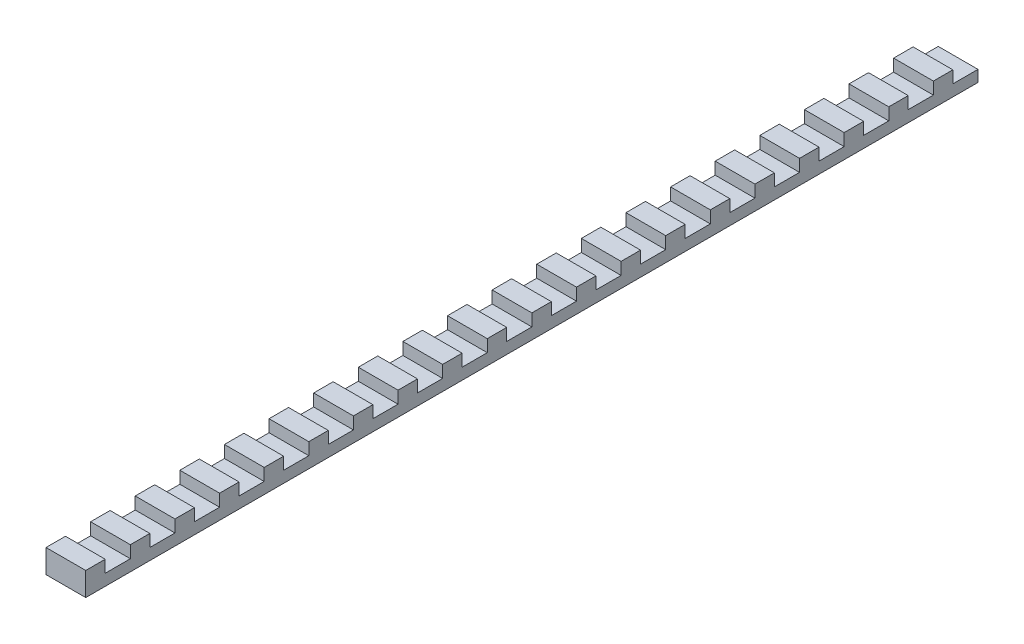
from build123d import *

# Parameters (mm, degrees)
BOSS_EXTRUDE1_DEPTH = 9.8
LPATTERN1_COUNT     = 20
LPATTERN1_PITCH     = 11


with BuildPart() as part:
    # Sketch1 → Boss-Extrude1 (new body)
    with BuildSketch(Plane(origin=(0, 0, 0), x_dir=(0, 0, -1), z_dir=(1, 0, 0))):
        Polygon((0, 0), (4.8, 0), (11, 0), (11, 2.8), (4.8, 2.8), (4.8, 5.8), (0, 5.8), align=None)
    boss_extrude1 = extrude(amount=BOSS_EXTRUDE1_DEPTH)

    # LPattern1: Boss-Extrude1 ×20
    with Locations(*[(0, 0, -i * LPATTERN1_PITCH) for i in range(1, LPATTERN1_COUNT)]):
        add(boss_extrude1)


solid = part.part
